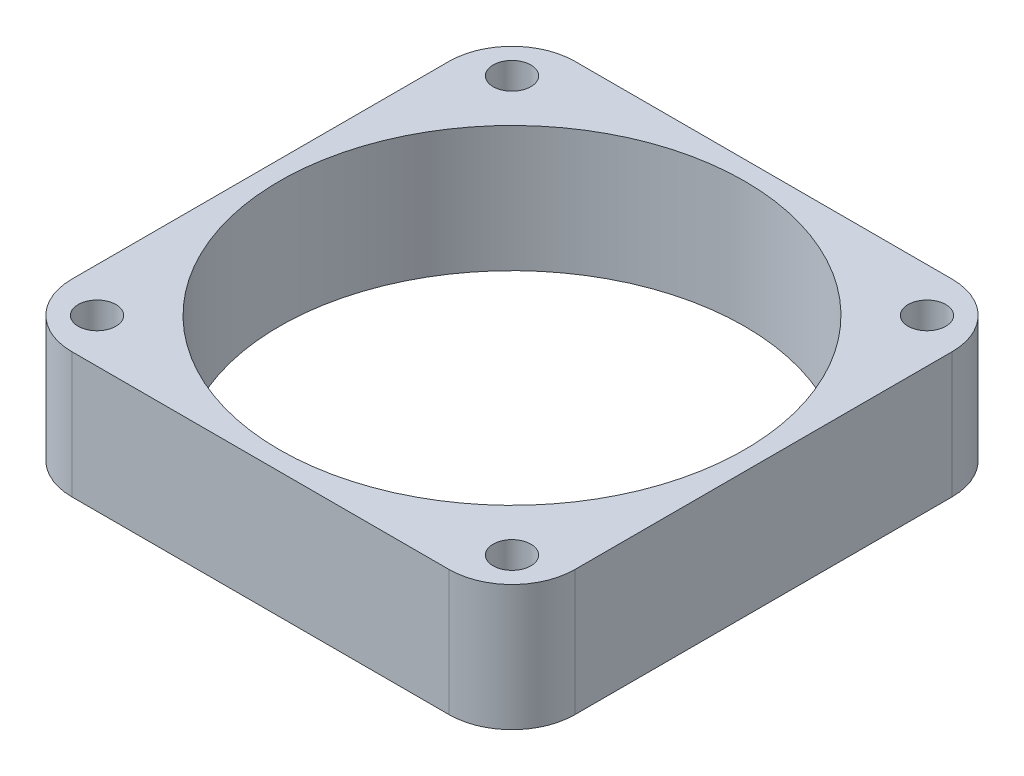
from build123d import *

# Parameters (mm, degrees)
SKETCH1_W           = 40
SKETCH1_H           = 40
BOSS_EXTRUDE1_DEPTH = 10
FILLET1_R           = 5
SKETCH2_R           = 18.5
CUT_EXTRUDE1_DEPTH  = 11
SKETCH3_R           = 1.5
CUT_EXTRUDE2_DEPTH  = 11


with BuildPart() as part:
    # Sketch1 → Boss-Extrude1 (new body)
    with BuildSketch(Plane(origin=(0, 0, 0), x_dir=(1, 0, 0), z_dir=(0, 1, 0))):
        Rectangle(SKETCH1_W, SKETCH1_H)
    extrude(amount=BOSS_EXTRUDE1_DEPTH)

    # Fillet1
    fillet1_edges = [part.edges().sort_by_distance(p)[0] for p in [
        (20, 5, 20),
        (-20, 5, 20),
        (-20, 5, -20),
        (20, 5, -20),
    ]]
    fillet(fillet1_edges, radius=FILLET1_R)

    # Sketch2 → Cut-Extrude1 (cut, through all)
    with BuildSketch(Plane(origin=(0, 10, 0), x_dir=(1, 0, 0), z_dir=(0, 1, 0))):
        Circle(SKETCH2_R)
    extrude(amount=-CUT_EXTRUDE1_DEPTH, mode=Mode.SUBTRACT)

    # Sketch3 → Cut-Extrude2 (cut, through all)
    with BuildSketch(Plane(origin=(0, 10, 0), x_dir=(1, 0, 0), z_dir=(0, 1, 0))):
        with Locations((-16.5, 16.5)):
            Circle(SKETCH3_R)
        with Locations((16.5, 16.5)):
            Circle(SKETCH3_R)
        with Locations((16.5, -16.5)):
            Circle(SKETCH3_R)
        with Locations((-16.5, -16.5)):
            Circle(SKETCH3_R)
    extrude(amount=-CUT_EXTRUDE2_DEPTH, mode=Mode.SUBTRACT)


solid = part.part
